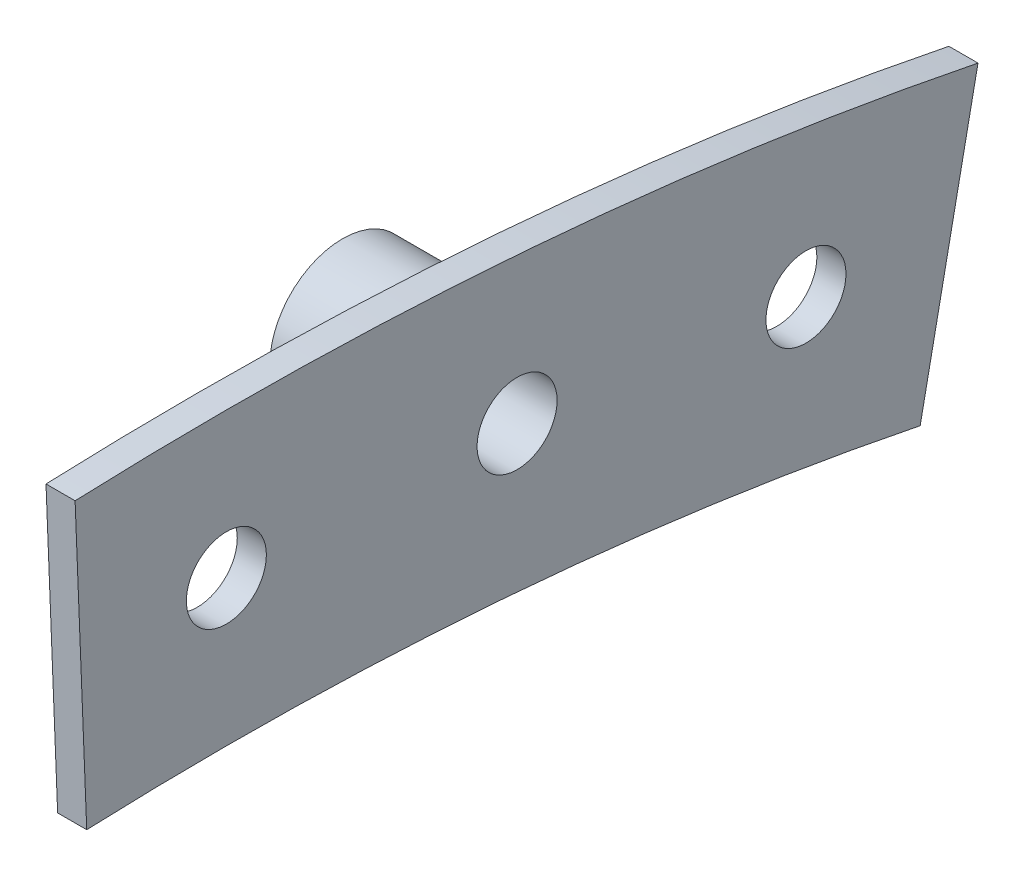
from build123d import *

# Parameters (mm, degrees)
SKETCH1_R           = 3.4925
BOSS_EXTRUDE1_DEPTH = 2.54
SKETCH2_R           = 6.35
BOSS_EXTRUDE2_DEPTH = 12.7
SKETCH4_R           = 3.4925
CUT_EXTRUDE1_DEPTH  = 6.35


with BuildPart() as part:
    # Sketch1 → Boss-Extrude1 (new body)
    with BuildSketch(Plane(origin=(0, 0, 0), x_dir=(0, 0, -1), z_dir=(1, 0, 0))):
        with BuildLine():
            Line((-12.189561356, 304.55616), (-13.205358136, 329.93584))
            ThreePointArc((-13.205358136, 329.93584), (26.39485874, 329.14336), (65.615293749, 323.615007727))
            Line((65.615293749, 323.615007727), (60.567963461, 298.721545594))
            ThreePointArc((60.567963461, 298.721545594), (24.364484991, 303.82464), (-12.189561356, 304.55616))
        make_face()
        with Locations((0, 317.5)):
            Circle(SKETCH1_R, mode=Mode.SUBTRACT)
        with Locations((25.379671865, 316.484)):
            Circle(SKETCH1_R, mode=Mode.SUBTRACT)
        with Locations((50.596913831, 313.4425024)):
            Circle(SKETCH1_R, mode=Mode.SUBTRACT)
    extrude(amount=BOSS_EXTRUDE1_DEPTH)

    # Sketch2 → Boss-Extrude2 (add)
    with BuildSketch(Plane.ZY):
        with Locations((-25.379671865, 316.484)):
            Circle(SKETCH2_R)
    extrude(amount=BOSS_EXTRUDE2_DEPTH)

    # Sketch4 → Cut-Extrude1 (cut)
    with BuildSketch(Plane(origin=(0, 0, 0), x_dir=(0, 0, -1), z_dir=(1, 0, 0))):
        with Locations((25.379671865, 316.484)):
            Circle(SKETCH4_R)
    extrude(amount=-CUT_EXTRUDE1_DEPTH, mode=Mode.SUBTRACT)


solid = part.part
